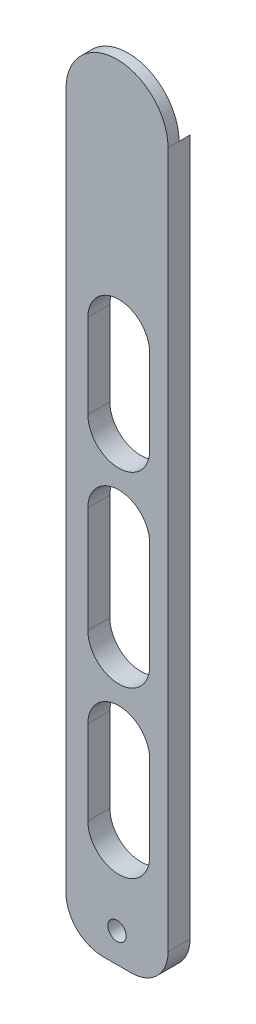
from build123d import *

# Parameters (mm, degrees)
ESQUISSE1_W             = 27.85
ESQUISSE1_H             = 200
BOSS_EXTRU_1_DEPTH      = 6
ESQUISSE4_R             = 2.5
ENL_V_MAT_EXTRU_3_DEPTH = 29
ESQUISSE5_R             = 13.925
ENL_V_MAT_EXTRU_4_DEPTH = 3
ESQUISSE7_W             = 16.87
ESQUISSE7_H             = 23
ESQUISSE7_H_2           = 29
ENL_V_MAT_EXTRU_6_DEPTH = 13
CONG_1_R                = 10
CONG_2_R                = 10


with BuildPart() as part:
    # Esquisse1 → Boss.-Extru.1 (new body)
    with BuildSketch(Plane.XY):
        with Locations((4.111190476, -68.237738095)):
            Rectangle(ESQUISSE1_W, ESQUISSE1_H)
        with BuildLine():
            Line((-9.813809524, 31.762261905), (18.036190476, 31.762261905))
            ThreePointArc((18.036190476, 31.762261905), (4.111190476, 45.687261905), (-9.813809524, 31.762261905))
        make_face()
    extrude(amount=BOSS_EXTRU_1_DEPTH)

    # Esquisse4 → Enlèv. mat.-Extru.3 (cut)
    with BuildSketch(Plane.XY.offset(6)):
        with Locations((4.111190476, -160.237738095)):
            Circle(ESQUISSE4_R)
    extrude(amount=-ENL_V_MAT_EXTRU_3_DEPTH, mode=Mode.SUBTRACT)

    # Esquisse5 → Enlèv. mat.-Extru.4 (cut)
    with BuildSketch(Plane(origin=(0, 0, 0), x_dir=(-1, 0, 0), z_dir=(0, 0, -1))):
        with Locations((-4.111190476, 31.762261905)):
            Circle(ESQUISSE5_R)
    extrude(amount=-ENL_V_MAT_EXTRU_4_DEPTH, mode=Mode.SUBTRACT)

    # Esquisse7 → Enlèv. mat.-Extru.6 (cut)
    with BuildSketch(Plane(origin=(0, 0, 0), x_dir=(-1, 0, 0), z_dir=(0, 0, -1))):
        with BuildLine():
            ThreePointArc((-13.036190476, -115.237738095), (-4.601190476, -106.802738095), (3.833809524, -115.237738095))
            Line((3.833809524, -115.237738095), (-13.036190476, -115.237738095))
        make_face()
        with Locations((-4.601190476, -126.737738095)):
            Rectangle(ESQUISSE7_W, ESQUISSE7_H)
        with BuildLine():
            Line((-13.036190476, -138.237738095), (3.833809524, -138.237738095))
            ThreePointArc((3.833809524, -138.237738095), (-4.601190476, -146.672738095), (-13.036190476, -138.237738095))
        make_face()
        with BuildLine():
            Line((3.833809524, -93.237738095), (-13.036190476, -93.237738095))
            ThreePointArc((-13.036190476, -93.237738095), (-4.601190476, -101.672738095), (3.833809524, -93.237738095))
        make_face()
        with Locations((-4.601190476, -78.737738095)):
            Rectangle(ESQUISSE7_W, ESQUISSE7_H_2)
        with BuildLine():
            Line((3.833809524, -64.237738095), (-13.036190476, -64.237738095))
            ThreePointArc((-13.036190476, -64.237738095), (-4.601190476, -55.802738095), (3.833809524, -64.237738095))
        make_face()
        with BuildLine():
            ThreePointArc((3.833809524, -42.237738095), (-4.601190476, -50.672738095), (-13.036190476, -42.237738095))
            Line((-13.036190476, -42.237738095), (3.833809524, -42.237738095))
        make_face()
        with Locations((-4.601190476, -30.737738095)):
            Rectangle(ESQUISSE7_W, ESQUISSE7_H)
        with BuildLine():
            Line((3.833809524, -19.237738095), (-13.036190476, -19.237738095))
            ThreePointArc((-13.036190476, -19.237738095), (-4.601190476, -10.802738095), (3.833809524, -19.237738095))
        make_face()
    extrude(amount=-ENL_V_MAT_EXTRU_6_DEPTH, mode=Mode.SUBTRACT)

    # Congé1
    cong_1_edges = [part.edges().sort_by_distance(p)[0] for p in [
        (18.036190476, -168.237738095, 3),
    ]]
    fillet(cong_1_edges, radius=CONG_1_R)

    # Congé2
    cong_2_edges = [part.edges().sort_by_distance(p)[0] for p in [
        (-9.813809524, -168.237738095, 3),
    ]]
    fillet(cong_2_edges, radius=CONG_2_R)


solid = part.part
